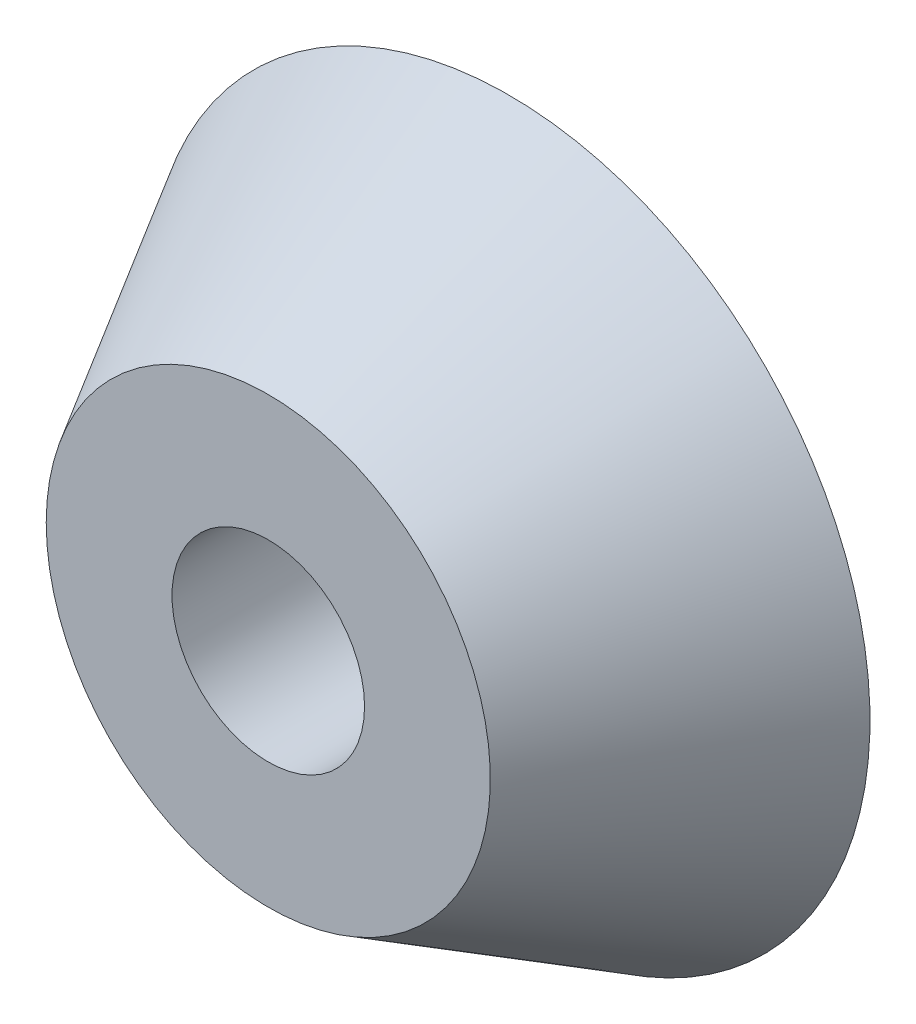
from build123d import *

# Parameters (mm, degrees)
SKETCH3_R          = 10
CUT_EXTRUDE1_DEPTH = 26


with BuildPart() as part:
    # Sketch2 → Revolve1 (revolve)
    with BuildSketch(Plane(origin=(0, 0, 0), x_dir=(1, 0, 0), z_dir=(0, 1, 0))):
        Polygon((0, 0), (23.06624327, 0), (37.5, 25), (0, 25), align=None)
    revolve(axis=Axis((0, 0, -25), (0, 0, 1)))

    # Sketch3 → Cut-Extrude1 (cut, through all)
    with BuildSketch(Plane.XY):
        Circle(SKETCH3_R)
    extrude(amount=-CUT_EXTRUDE1_DEPTH, mode=Mode.SUBTRACT)


solid = part.part
